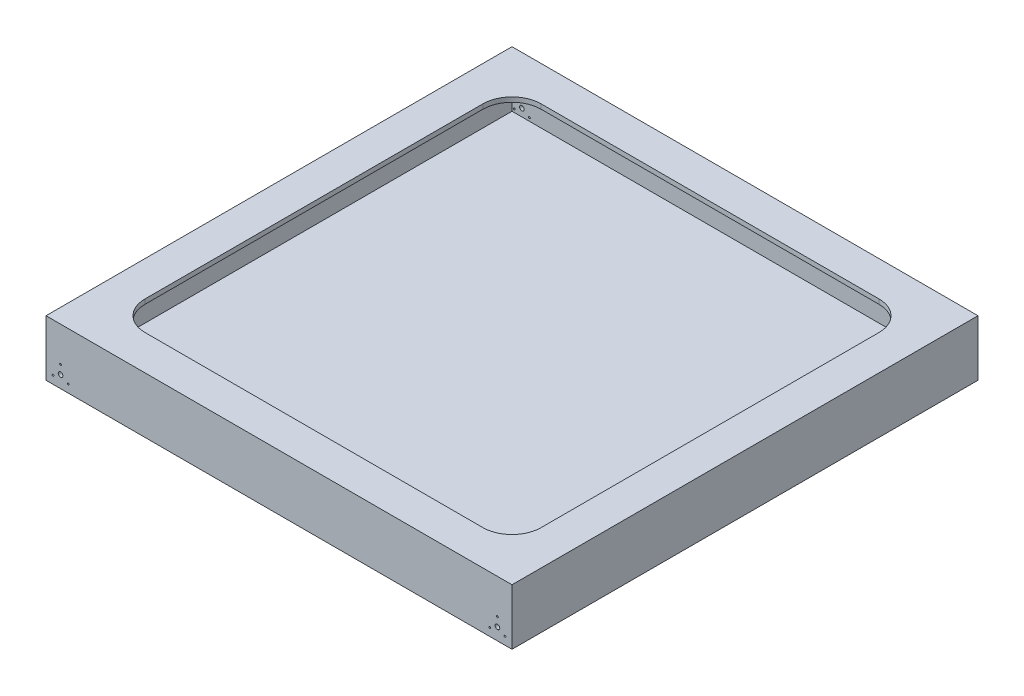
from build123d import *

# Parameters (mm, degrees)
SKETCH1_W           = 800
SKETCH1_H           = 800
BOSS_EXTRUDE1_DEPTH = 8
SKETCH2_W           = 800
SKETCH2_H           = 800
SKETCH2_W_2         = 784
SKETCH2_H_2         = 784
BOSS_EXTRUDE2_DEPTH = 80
SKETCH3_W           = 800
SKETCH3_H           = 800
BOSS_EXTRUDE3_DEPTH = 8
SKETCH4_R           = 4
CUT_EXTRUDE1_DEPTH  = 800
SKETCH5_R           = 1.5
CUT_EXTRUDE2_DEPTH  = 800
SKETCH6_R           = 4
CUT_EXTRUDE3_DEPTH  = 10


with BuildPart() as part:
    # Sketch1 → Boss-Extrude1 (new body)
    with BuildSketch(Plane(origin=(0, 0, 0), x_dir=(1, 0, 0), z_dir=(0, 1, 0))):
        Rectangle(SKETCH1_W, SKETCH1_H)
    extrude(amount=BOSS_EXTRUDE1_DEPTH)

    # Sketch2 → Boss-Extrude2 (add)
    with BuildSketch(Plane(origin=(0, 8, 0), x_dir=(1, 0, 0), z_dir=(0, 1, 0))):
        Rectangle(SKETCH2_W, SKETCH2_H)
        Rectangle(SKETCH2_W_2, SKETCH2_H_2, mode=Mode.SUBTRACT)
    extrude(amount=BOSS_EXTRUDE2_DEPTH)

    # Sketch3 → Boss-Extrude3 (add)
    with BuildSketch(Plane(origin=(0, 88, 0), x_dir=(1, 0, 0), z_dir=(0, 1, 0))):
        Rectangle(SKETCH3_W, SKETCH3_H)
        with BuildLine():
            Line((290, -340), (-290, -340))
            ThreePointArc((-290, -340), (-325.355339059, -325.355339059), (-340, -290))
            Line((-340, -290), (-340, 290))
            ThreePointArc((-340, 290), (-325.355339059, 325.355339059), (-290, 340))
            Line((-290, 340), (290, 340))
            ThreePointArc((290, 340), (325.355339059, 325.355339059), (340, 290))
            Line((340, 290), (340, -290))
            ThreePointArc((340, -290), (325.355339059, -325.355339059), (290, -340))
        make_face(mode=Mode.SUBTRACT)
    extrude(amount=BOSS_EXTRUDE3_DEPTH)

    # Sketch4 → Cut-Extrude1 (cut)
    with BuildSketch(Plane.XY.offset(400)):
        with Locations((-375, 21)):
            Circle(SKETCH4_R)
        with Locations((375, 21)):
            Circle(SKETCH4_R)
    extrude(amount=-CUT_EXTRUDE1_DEPTH, mode=Mode.SUBTRACT)

    # Sketch5 → Cut-Extrude2 (cut)
    with BuildSketch(Plane.XY.offset(400)):
        with Locations((-375, 36)):
            Circle(SKETCH5_R)
        with Locations((-387.990381057, 13.5)):
            Circle(SKETCH5_R)
        with Locations((-362.009618943, 13.5)):
            Circle(SKETCH5_R)
        with Locations((362.009618943, 13.5)):
            Circle(SKETCH5_R)
        with Locations((387.990381057, 13.5)):
            Circle(SKETCH5_R)
        with Locations((375, 36)):
            Circle(SKETCH5_R)
    extrude(amount=-CUT_EXTRUDE2_DEPTH, mode=Mode.SUBTRACT)

    # Sketch6 → Cut-Extrude3 (cut)
    with BuildSketch(Plane(origin=(0, 0, 0), x_dir=(-1, 0, 0), z_dir=(0, -1, 0))):
        with Locations((-346.85, -358.85)):
            Circle(SKETCH6_R)
        with Locations((346.85, -358.85)):
            Circle(SKETCH6_R)
    extrude(amount=-CUT_EXTRUDE3_DEPTH, mode=Mode.SUBTRACT)


solid = part.part
